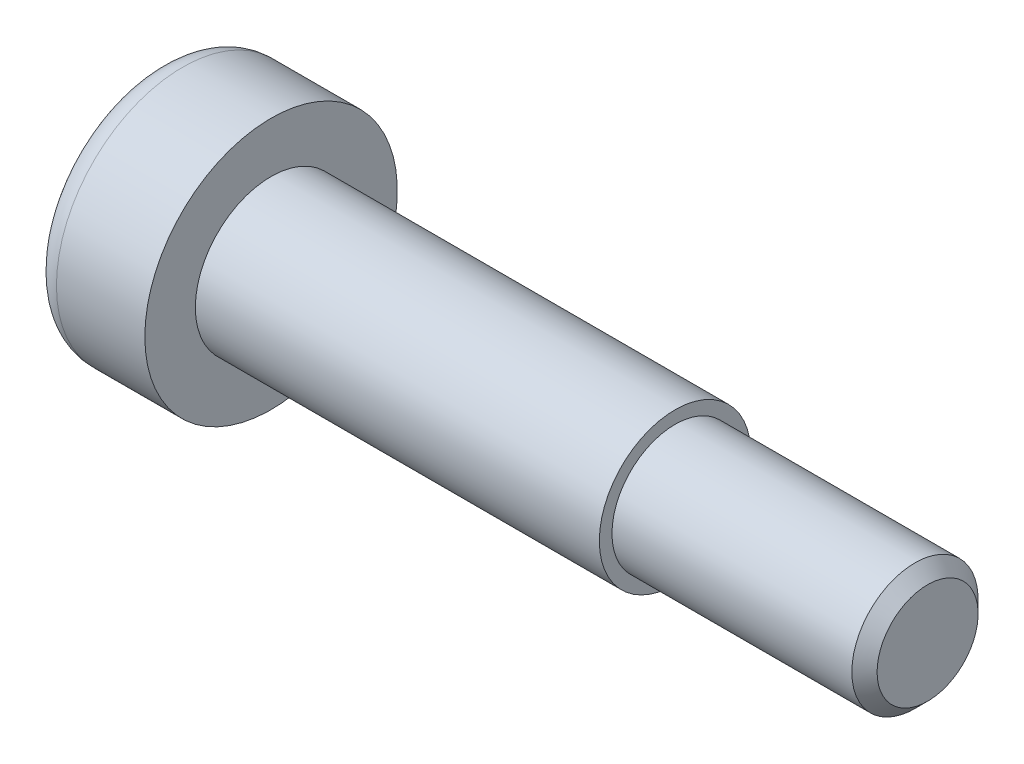
from build123d import *

# Parameters (mm, degrees)
CUT_EXTRUDE_1_DEPTH = 3
FILLET_1_R          = 1
CHAMFER_1_SIZE      = 0.5


with BuildPart() as part:
    # 草图1 → 旋转1 (revolve)
    with BuildSketch(Plane.XY):
        Polygon((0, 0), (0, 5), (4.5, 5), (4.5, 3), (20.5, 3), (20.5, 2.5), (30.5, 2.5), (30.5, 0), align=None)
    revolve(axis=Axis((0, 0, 0), (1, 0, 0)))

    # 草图2 → 切除-拉伸1 (cut)
    with BuildSketch(Plane.ZY):
        Polygon((0, 1.732050808), (-1.5, 0.866025404), (-1.5, -0.866025404), (0, -1.732050808), (1.5, -0.866025404), (1.5, 0.866025404), align=None)
    extrude(amount=-CUT_EXTRUDE_1_DEPTH, mode=Mode.SUBTRACT)

    # 圆角1
    fillet_1_edges = [part.edges().sort_by_distance(p)[0] for p in [
        (0, -5, 0),
    ]]
    fillet(fillet_1_edges, radius=FILLET_1_R)

    # 倒角1
    chamfer_1_edges = [part.edges().sort_by_distance(p)[0] for p in [
        (30.5, -2.5, 0),
    ]]
    chamfer(chamfer_1_edges, length=CHAMFER_1_SIZE)


solid = part.part
